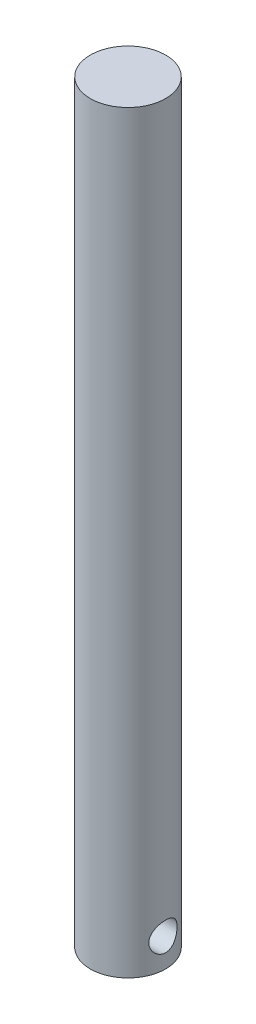
from build123d import *

# Parameters (mm, degrees)
SKETCH1_R               = 20
BOSS_EXTRUDE1_DEPTH     = 400
SKETCH2_R               = 7.5
CUT_EXTRUDE1_DEPTH      = 21
CUT_EXTRUDE1_DEPTH_BACK = 21


with BuildPart() as part:
    # Sketch1 → Boss-Extrude1 (new body)
    with BuildSketch(Plane(origin=(0, 0, 0), x_dir=(1, 0, 0), z_dir=(0, 1, 0))):
        Circle(SKETCH1_R)
    extrude(amount=BOSS_EXTRUDE1_DEPTH)

    # Sketch2 → Cut-Extrude1 (cut, two sides)
    with BuildSketch(Plane(origin=(0, 0, 0), x_dir=(0, 0, -1), z_dir=(1, 0, 0))) as cut_extrude1_sk:
        with Locations((0, 15)):
            Circle(SKETCH2_R)
    extrude(amount=CUT_EXTRUDE1_DEPTH, mode=Mode.SUBTRACT)
    extrude(cut_extrude1_sk.sketch, amount=-CUT_EXTRUDE1_DEPTH_BACK, mode=Mode.SUBTRACT)


solid = part.part
